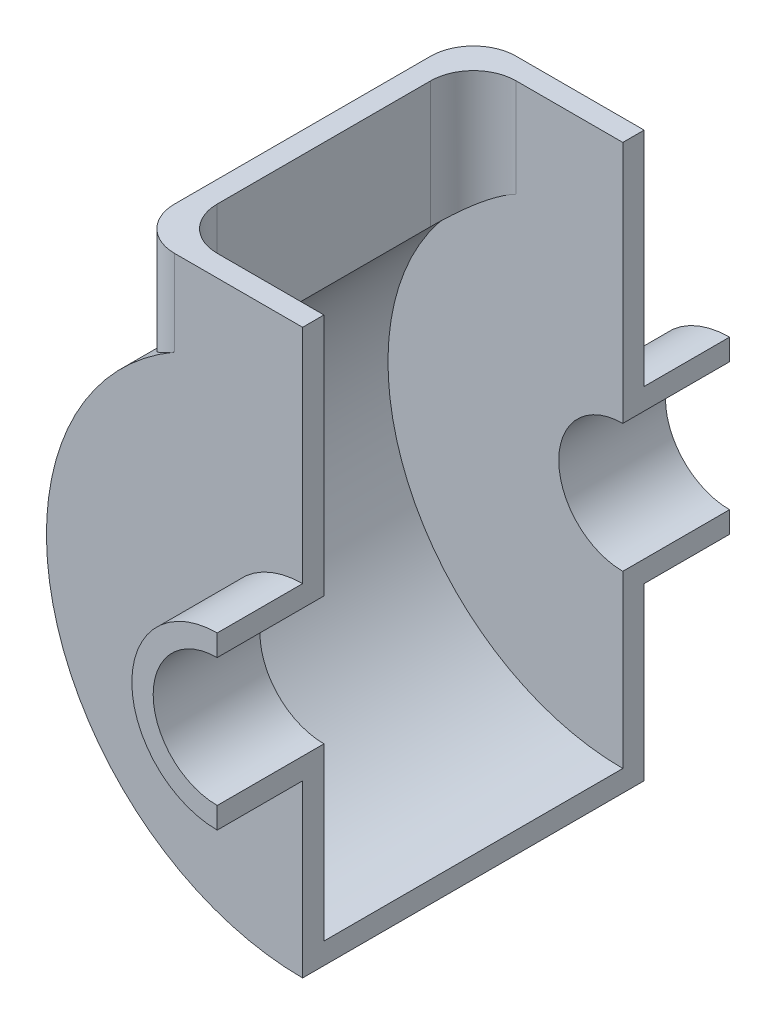
from build123d import *

# Parameters (mm, degrees)
DODANIE_WYCI_GNI_CIE1_DEPTH       = 25
DODANIE_WYCI_GNI_CIE2_DEPTH       = 5
WYCI_GNI_CIE_CIENKA_START         = -70
WYCI_GNI_CIE_CIENKA_CIANKA4_DEPTH = 70
ZAOKR_GLENIE2_R                   = 10


with BuildPart() as part:
    # Szkic1 → Dodanie-wyciągnięcie1 (new body)
    with BuildSketch(Plane.XY):
        with BuildLine():
            Line((0, 20), (0, 15))
            ThreePointArc((0, 15), (-15, 0), (0, -15))
            Line((0, -15), (0, -20))
            ThreePointArc((0, -20), (-20, 0), (0, 20))
        make_face()
    extrude(amount=DODANIE_WYCI_GNI_CIE1_DEPTH)

    # Szkic2 → Dodanie-wyciągnięcie2 (add)
    with BuildSketch(Plane.XY):
        with BuildLine():
            Line((0, 72), (0, 20))
            Line((0, 20), (0, 15))
            ThreePointArc((0, 15), (-15, 0), (0, -15))
            Line((0, -15), (0, -20))
            Line((0, -20), (0, -60))
            ThreePointArc((0, -60), (-56.050341538, -21.409325386), (-40, 44.72135955))
            Line((-40, 44.72135955), (-40, 72))
            Line((-40, 72), (0, 72))
        make_face()
    extrude(amount=DODANIE_WYCI_GNI_CIE2_DEPTH)


with BuildPart() as body_2:
    # Lustro1: mirrored copy
    add(part.part.mirror(Plane.XY.offset(-35)))


with BuildPart() as part_1:
    add(part.part)

    add(body_2.part)  # Wyciągnięcie-cienka ścianka4 merges body 2
    # Szkic7 → Wyciągnięcie-cienka ścianka4 (add)
    with BuildSketch(Plane.XY.offset(WYCI_GNI_CIE_CIENKA_START)):
        with BuildLine():
            Line((-40, 72), (-40, 44.72135955))
            ThreePointArc((-40, 44.72135955), (-56.050341538, -21.409325386), (0, -60))
            Line((0, -60), (0, -55))
            ThreePointArc((0, -55), (-51.76124215, -18.594994247), (-35, 42.426406871))
            Line((-35, 42.426406871), (-35, 72))
            Line((-35, 72), (-40, 72))
        make_face()
    extrude(amount=WYCI_GNI_CIE_CIENKA_CIANKA4_DEPTH)

    # Zaokrąglenie2
    zaokr_glenie2_edges = [part_1.edges().sort_by_distance(p)[0] for p in [
        (-40, 58.360679775, 5),
        (-35, 57.213203436, -70),
        (-35, 57.213203436, 0),
        (-40, 58.360679775, -75),
    ]]
    fillet(zaokr_glenie2_edges, radius=ZAOKR_GLENIE2_R)


solid = part_1.part
